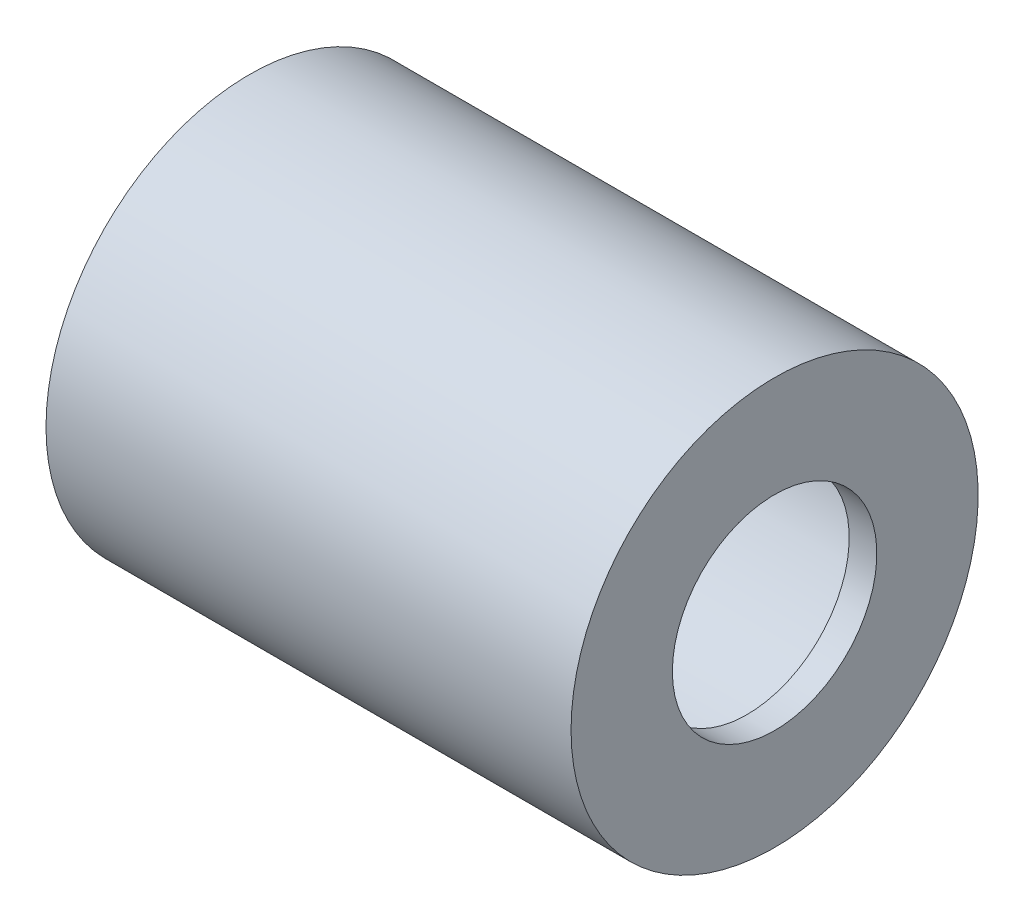
from build123d import *


with BuildPart() as part:
    # Sketch1 → Revolve1 (revolve)
    with BuildSketch(Plane.XY):
        Polygon((19.408906872, 9.006172878), (22.408906872, 9.006172878), (22.408906872, 20.006172878), (19.408906872, 20.006172878), (-34.597518993, 20.006172878), (-34.597518993, 17.006172878), (19.408906872, 17.006172878), align=None)
    revolve(axis=Axis((-16.762687395, -2.093827122, 0), (1, 0, 0)))


solid = part.part
